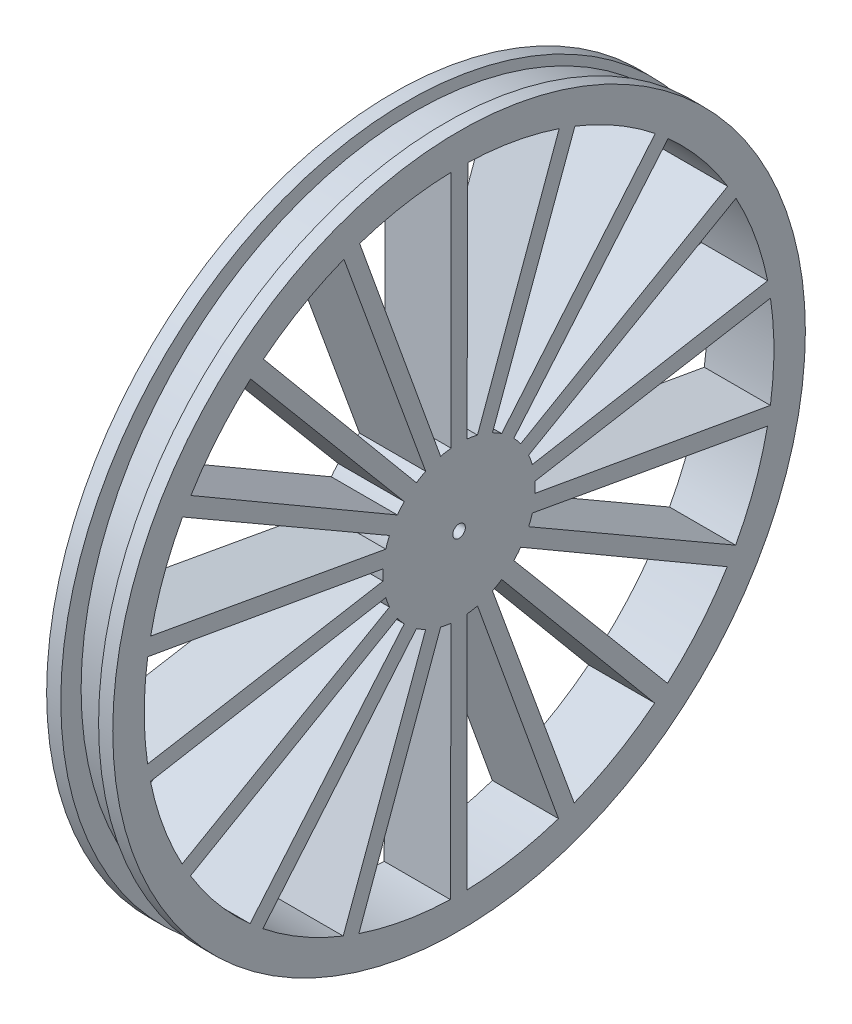
from build123d import *

# Parameters (mm, degrees)
SKETCH3_R                = 55
BOSS_EXTRUDE4_DEPTH      = 7
SKETCH4_R                = 55
SKETCH4_R_2              = 1
BOSS_EXTRUDE6_DEPTH      = 3.5
BOSS_EXTRUDE6_DEPTH_BACK = 1


with BuildPart() as part:
    # Sketch3 → Boss-Extrude4 (new body)
    with BuildSketch(Plane(origin=(0, 0, 0), x_dir=(0, 0, -1), z_dir=(1, 0, 0))):
        Circle(SKETCH3_R)
        with BuildLine():
            ThreePointArc((-6.766234132, -10.031354628), (-6.05, -10.478907386), (-5.304290876, -10.87540796))
            Line((-5.304290876, -10.87540796), (-18.398622374, -46.49183471))
            ThreePointArc((-18.398622374, -46.49183471), (-25.053308564, -43.270448692), (-31.160207408, -39.102959917))
            Line((-31.160207408, -39.102959917), (-6.766234132, -10.031354628))
        make_face(mode=Mode.SUBTRACT)
        with BuildLine():
            ThreePointArc((-2.927254937, -11.740578288), (-2.10114295, -11.916173811), (-1.264794406, -12.033714934))
            Line((-1.264794406, -12.033714934), (-1.387905707, -49.980733465))
            ThreePointArc((-1.387905707, -49.980733465), (-8.743044121, -49.22965752), (-15.907017008, -47.402181489))
            Line((-15.907017008, -47.402181489), (-2.927254937, -11.740578288))
        make_face(mode=Mode.SUBTRACT)
        with BuildLine():
            ThreePointArc((-11.631266521, -3.335212005), (-11.370280712, -4.138443734), (-11.053900037, -4.921513381))
            Line((-11.053900037, -4.921513381), (-43.978537734, -23.788405133))
            ThreePointArc((-43.978537734, -23.788405133), (-47.005656092, -17.043130445), (-49.005001868, -9.925209917))
            Line((-49.005001868, -9.925209917), (-11.631266521, -3.335212005))
        make_face(mode=Mode.SUBTRACT)
        with BuildLine():
            ThreePointArc((-9.789105632, -7.112201553), (-9.269137762, -7.777730077), (-8.704011584, -8.405366283))
            Line((-8.704011584, -8.405366283), (-33.190193649, -37.395334543))
            ThreePointArc((-33.190193649, -37.395334543), (-38.341774248, -32.092185148), (-42.655016919, -26.087344281))
            Line((-42.655016919, -26.087344281), (-9.789105632, -7.112201553))
        make_face(mode=Mode.SUBTRACT)
        with BuildLine():
            ThreePointArc((1.264794406, -12.033714934), (2.10114295, -11.916173811), (2.927254937, -11.740578288))
            Line((2.927254937, -11.740578288), (15.790212872, -47.441218128))
            ThreePointArc((15.790212872, -47.441218128), (8.621760477, -49.251043098), (1.264794406, -49.984000391))
            Line((1.264794406, -49.984000391), (1.264794406, -12.033714934))
        make_face(mode=Mode.SUBTRACT)
        with BuildLine():
            ThreePointArc((5.304290876, -10.87540796), (6.05, -10.478907386), (6.766234132, -10.031354628))
            Line((6.766234132, -10.031354628), (31.06379874, -39.179591726))
            ThreePointArc((31.06379874, -39.179591726), (24.946653518, -43.332026011), (18.284052947, -46.537011161))
            Line((18.284052947, -46.537011161), (5.304290876, -10.87540796))
        make_face(mode=Mode.SUBTRACT)
        with BuildLine():
            ThreePointArc((8.704011584, -8.405366283), (9.269137762, -7.777730077), (9.789105632, -7.112201553))
            Line((9.789105632, -7.112201553), (42.590632028, -26.192328333))
            ThreePointArc((42.590632028, -26.192328333), (38.262611971, -32.186527075), (33.09798486, -37.476971572))
            Line((33.09798486, -37.476971572), (8.704011584, -8.405366283))
        make_face(mode=Mode.SUBTRACT)
        with BuildLine():
            ThreePointArc((11.053900037, -4.921513381), (11.370280712, -4.138443734), (11.631266521, -3.335212005))
            Line((11.631266521, -3.335212005), (48.980406521, -10.045883585))
            ThreePointArc((48.980406521, -10.045883585), (46.963534725, -17.158857951), (43.919811324, -23.89665611))
            Line((43.919811324, -23.89665611), (11.053900037, -4.921513381))
        make_face(mode=Mode.SUBTRACT)
        with BuildLine():
            ThreePointArc((12.070525008, -0.844053332), (12.1, 0), (12.070525008, 0.844053332))
            Line((12.070525008, 0.844053332), (49.462421115, 7.312242984))
            ThreePointArc((49.462421115, 7.312242984), (49.809734905, 4.357787137), (49.980733465, 1.387905707))
            ThreePointArc((49.980733465, 1.387905707), (50, 0), (49.980733465, -1.387905707))
            ThreePointArc((49.980733465, -1.387905707), (49.804330314, -4.419126832), (49.444260356, -7.434051244))
            Line((49.444260356, -7.434051244), (12.070525008, -0.844053332))
        make_face(mode=Mode.SUBTRACT)
        with BuildLine():
            ThreePointArc((-12.070525008, 0.844053332), (-12.1, 0), (-12.070525008, -0.844053332))
            Line((-12.070525008, -0.844053332), (-49.462421115, -7.312242984))
            ThreePointArc((-49.462421115, -7.312242984), (-49.809734905, -4.357787137), (-49.980733465, -1.387905707))
            ThreePointArc((-49.980733465, -1.387905707), (-50, 0), (-49.980733465, 1.387905707))
            ThreePointArc((-49.980733465, 1.387905707), (-49.804330314, 4.419126832), (-49.444260356, 7.434051244))
            Line((-49.444260356, 7.434051244), (-12.070525008, 0.844053332))
        make_face(mode=Mode.SUBTRACT)
        with BuildLine():
            ThreePointArc((-11.053900037, 4.921513381), (-11.370280712, 4.138443734), (-11.631266521, 3.335212005))
            Line((-11.631266521, 3.335212005), (-48.980406521, 10.045883585))
            ThreePointArc((-48.980406521, 10.045883585), (-46.963534725, 17.158857951), (-43.919811324, 23.89665611))
            Line((-43.919811324, 23.89665611), (-11.053900037, 4.921513381))
        make_face(mode=Mode.SUBTRACT)
        with BuildLine():
            ThreePointArc((-8.704011584, 8.405366283), (-9.269137762, 7.777730077), (-9.789105632, 7.112201553))
            Line((-9.789105632, 7.112201553), (-42.590632028, 26.192328333))
            ThreePointArc((-42.590632028, 26.192328333), (-38.262611971, 32.186527075), (-33.09798486, 37.476971572))
            Line((-33.09798486, 37.476971572), (-8.704011584, 8.405366283))
        make_face(mode=Mode.SUBTRACT)
        with BuildLine():
            ThreePointArc((-5.304290876, 10.87540796), (-6.05, 10.478907386), (-6.766234132, 10.031354628))
            Line((-6.766234132, 10.031354628), (-31.06379874, 39.179591726))
            ThreePointArc((-31.06379874, 39.179591726), (-24.946653518, 43.332026011), (-18.284052947, 46.537011161))
            Line((-18.284052947, 46.537011161), (-5.304290876, 10.87540796))
        make_face(mode=Mode.SUBTRACT)
        with BuildLine():
            Line((-1.264794406, 49.984000391), (-1.264794406, 12.033714934))
            ThreePointArc((-1.264794406, 12.033714934), (-2.10114295, 11.916173811), (-2.927254937, 11.740578288))
            Line((-2.927254937, 11.740578288), (-15.790212872, 47.441218128))
            ThreePointArc((-15.790212872, 47.441218128), (-8.621760477, 49.251043098), (-1.264794406, 49.984000391))
        make_face(mode=Mode.SUBTRACT)
        Polygon((-0.586190908, 5.577233937), (0, 8.1), (0.586190908, 5.577233937), (1.684084696, 7.922995566), (1.732953368, 5.333482051), (3.294566809, 7.399718207), (2.80397745, 4.856631407), (4.761060544, 6.553037654), (3.752454263, 4.167522666), (6.019473086, 5.419957912), (4.536930818, 3.296273186), (7.014805771, 4.05), (5.123121726, 2.280960751), (7.703557782, 2.503037654), (5.485407631, 1.165959385), (8.055627352, 0.846680552), (5.607954901, 0), (8.055627352, -0.846680552), (5.485407631, -1.165959385), (7.703557782, -2.503037654), (5.123121726, -2.280960751), (7.014805771, -4.05), (4.536930818, -3.296273186), (6.019473086, -5.419957912), (3.752454263, -4.167522666), (4.761060544, -6.553037654), (2.80397745, -4.856631407), (3.294566809, -7.399718207), (1.732953368, -5.333482051), (1.684084696, -7.922995566), (0.586190908, -5.577233937), (0, -8.1), (-0.586190908, -5.577233937), (-1.684084696, -7.922995566), (-1.732953368, -5.333482051), (-3.294566809, -7.399718207), (-2.80397745, -4.856631407), (-4.761060544, -6.553037654), (-3.752454263, -4.167522666), (-6.019473086, -5.419957912), (-4.536930818, -3.296273186), (-7.014805771, -4.05), (-5.123121726, -2.280960751), (-7.703557782, -2.503037654), (-5.485407631, -1.165959385), (-8.055627352, -0.846680552), (-5.607954901, 0), (-8.055627352, 0.846680552), (-5.485407631, 1.165959385), (-7.703557782, 2.503037654), (-5.123121726, 2.280960751), (-7.014805771, 4.05), (-4.536930818, 3.296273186), (-6.019473086, 5.419957912), (-3.752454263, 4.167522666), (-4.761060544, 6.553037654), (-2.80397745, 4.856631407), (-3.294566809, 7.399718207), (-1.732953368, 5.333482051), (-1.684084696, 7.922995566), align=None, mode=Mode.SUBTRACT)
        with BuildLine():
            ThreePointArc((9.789105632, 7.112201553), (9.269137762, 7.777730077), (8.704011584, 8.405366283))
            Line((8.704011584, 8.405366283), (33.190193649, 37.395334543))
            ThreePointArc((33.190193649, 37.395334543), (38.341774248, 32.092185148), (42.655016919, 26.087344281))
            Line((42.655016919, 26.087344281), (9.789105632, 7.112201553))
        make_face(mode=Mode.SUBTRACT)
        with BuildLine():
            Line((11.053900037, 4.921513381), (43.978537734, 23.788405133))
            ThreePointArc((43.978537734, 23.788405133), (47.005656092, 17.043130445), (49.005001868, 9.925209917))
            Line((49.005001868, 9.925209917), (11.631266521, 3.335212005))
            ThreePointArc((11.631266521, 3.335212005), (11.370280712, 4.138443734), (11.053900037, 4.921513381))
        make_face(mode=Mode.SUBTRACT)
        with BuildLine():
            Line((15.907017008, 47.402181489), (2.927254937, 11.740578288))
            ThreePointArc((2.927254937, 11.740578288), (2.10114295, 11.916173811), (1.264794406, 12.033714934))
            Line((1.264794406, 12.033714934), (1.387905707, 49.980733465))
            ThreePointArc((1.387905707, 49.980733465), (8.743044121, 49.22965752), (15.907017008, 47.402181489))
        make_face(mode=Mode.SUBTRACT)
        with BuildLine():
            ThreePointArc((6.766234132, 10.031354628), (6.05, 10.478907386), (5.304290876, 10.87540796))
            Line((5.304290876, 10.87540796), (18.398622374, 46.49183471))
            ThreePointArc((18.398622374, 46.49183471), (25.053308564, 43.270448692), (31.160207408, 39.102959917))
            Line((31.160207408, 39.102959917), (6.766234132, 10.031354628))
        make_face(mode=Mode.SUBTRACT)
    extrude(amount=BOSS_EXTRUDE4_DEPTH)

    # Sketch4 → Boss-Extrude6 (add, two sides)
    with BuildSketch(Plane(origin=(7, 0, 0), x_dir=(0, 0, -1), z_dir=(1, 0, 0))) as boss_extrude6_sk:
        Circle(SKETCH4_R)
        with BuildLine():
            ThreePointArc((-11.053900037, 4.921513381), (-11.370280712, 4.138443734), (-11.631266521, 3.335212005))
            Line((-11.631266521, 3.335212005), (-48.980406521, 10.045883585))
            ThreePointArc((-48.980406521, 10.045883585), (-46.963534725, 17.158857951), (-43.919811324, 23.89665611))
            Line((-43.919811324, 23.89665611), (-11.053900037, 4.921513381))
        make_face(mode=Mode.SUBTRACT)
        with BuildLine():
            ThreePointArc((-8.704011584, 8.405366283), (-9.269137762, 7.777730077), (-9.789105632, 7.112201553))
            Line((-9.789105632, 7.112201553), (-42.590632028, 26.192328333))
            ThreePointArc((-42.590632028, 26.192328333), (-38.262611971, 32.186527075), (-33.09798486, 37.476971572))
            Line((-33.09798486, 37.476971572), (-8.704011584, 8.405366283))
        make_face(mode=Mode.SUBTRACT)
        with BuildLine():
            ThreePointArc((-5.304290876, 10.87540796), (-6.05, 10.478907386), (-6.766234132, 10.031354628))
            Line((-6.766234132, 10.031354628), (-31.06379874, 39.179591726))
            ThreePointArc((-31.06379874, 39.179591726), (-24.946653518, 43.332026011), (-18.284052947, 46.537011161))
            Line((-18.284052947, 46.537011161), (-5.304290876, 10.87540796))
        make_face(mode=Mode.SUBTRACT)
        with BuildLine():
            ThreePointArc((-1.264794406, 12.033714934), (-2.10114295, 11.916173811), (-2.927254937, 11.740578288))
            Line((-2.927254937, 11.740578288), (-15.790212872, 47.441218128))
            ThreePointArc((-15.790212872, 47.441218128), (-8.621760477, 49.251043098), (-1.264794406, 49.984000391))
            Line((-1.264794406, 49.984000391), (-1.264794406, 12.033714934))
        make_face(mode=Mode.SUBTRACT)
        with BuildLine():
            ThreePointArc((2.927254937, 11.740578288), (2.10114295, 11.916173811), (1.264794406, 12.033714934))
            Line((1.264794406, 12.033714934), (1.387905707, 49.980733465))
            ThreePointArc((1.387905707, 49.980733465), (8.743044121, 49.22965752), (15.907017008, 47.402181489))
            Line((15.907017008, 47.402181489), (2.927254937, 11.740578288))
        make_face(mode=Mode.SUBTRACT)
        with BuildLine():
            ThreePointArc((6.766234132, 10.031354628), (6.05, 10.478907386), (5.304290876, 10.87540796))
            Line((5.304290876, 10.87540796), (18.398622374, 46.49183471))
            ThreePointArc((18.398622374, 46.49183471), (25.053308564, 43.270448692), (31.160207408, 39.102959917))
            Line((31.160207408, 39.102959917), (6.766234132, 10.031354628))
        make_face(mode=Mode.SUBTRACT)
        with BuildLine():
            ThreePointArc((9.789105632, 7.112201553), (9.269137762, 7.777730077), (8.704011584, 8.405366283))
            Line((8.704011584, 8.405366283), (33.190193649, 37.395334543))
            ThreePointArc((33.190193649, 37.395334543), (38.341774248, 32.092185148), (42.655016919, 26.087344281))
            Line((42.655016919, 26.087344281), (9.789105632, 7.112201553))
        make_face(mode=Mode.SUBTRACT)
        with BuildLine():
            ThreePointArc((11.631266521, 3.335212005), (11.370280712, 4.138443734), (11.053900037, 4.921513381))
            Line((11.053900037, 4.921513381), (43.978537734, 23.788405133))
            ThreePointArc((43.978537734, 23.788405133), (47.005656092, 17.043130445), (49.005001868, 9.925209917))
            Line((49.005001868, 9.925209917), (11.631266521, 3.335212005))
        make_face(mode=Mode.SUBTRACT)
        with BuildLine():
            Line((12.070525008, 0.844053332), (49.462421115, 7.312242984))
            ThreePointArc((49.462421115, 7.312242984), (49.999962082, -0.06157732), (49.444260356, -7.434051244))
            Line((49.444260356, -7.434051244), (12.070525008, -0.844053332))
            ThreePointArc((12.070525008, -0.844053332), (12.1, 0), (12.070525008, 0.844053332))
        make_face(mode=Mode.SUBTRACT)
        with BuildLine():
            ThreePointArc((11.053900037, -4.921513381), (11.370280712, -4.138443734), (11.631266521, -3.335212005))
            Line((11.631266521, -3.335212005), (48.980406521, -10.045883585))
            ThreePointArc((48.980406521, -10.045883585), (46.963534725, -17.158857951), (43.919811324, -23.89665611))
            Line((43.919811324, -23.89665611), (11.053900037, -4.921513381))
        make_face(mode=Mode.SUBTRACT)
        with BuildLine():
            ThreePointArc((8.704011584, -8.405366283), (9.269137762, -7.777730077), (9.789105632, -7.112201553))
            Line((9.789105632, -7.112201553), (42.590632028, -26.192328333))
            ThreePointArc((42.590632028, -26.192328333), (38.262611971, -32.186527075), (33.09798486, -37.476971572))
            Line((33.09798486, -37.476971572), (8.704011584, -8.405366283))
        make_face(mode=Mode.SUBTRACT)
        with BuildLine():
            ThreePointArc((5.304290876, -10.87540796), (6.05, -10.478907386), (6.766234132, -10.031354628))
            Line((6.766234132, -10.031354628), (31.06379874, -39.179591726))
            ThreePointArc((31.06379874, -39.179591726), (24.946653518, -43.332026011), (18.284052947, -46.537011161))
            Line((18.284052947, -46.537011161), (5.304290876, -10.87540796))
        make_face(mode=Mode.SUBTRACT)
        with BuildLine():
            ThreePointArc((1.264794406, -12.033714934), (2.10114295, -11.916173811), (2.927254937, -11.740578288))
            Line((2.927254937, -11.740578288), (15.790212872, -47.441218128))
            ThreePointArc((15.790212872, -47.441218128), (8.621760477, -49.251043098), (1.264794406, -49.984000391))
            Line((1.264794406, -49.984000391), (1.264794406, -12.033714934))
        make_face(mode=Mode.SUBTRACT)
        with BuildLine():
            ThreePointArc((-2.927254937, -11.740578288), (-2.10114295, -11.916173811), (-1.264794406, -12.033714934))
            Line((-1.264794406, -12.033714934), (-1.387905707, -49.980733465))
            ThreePointArc((-1.387905707, -49.980733465), (-8.743044121, -49.22965752), (-15.907017008, -47.402181489))
            Line((-15.907017008, -47.402181489), (-2.927254937, -11.740578288))
        make_face(mode=Mode.SUBTRACT)
        with BuildLine():
            ThreePointArc((-6.766234132, -10.031354628), (-6.05, -10.478907386), (-5.304290876, -10.87540796))
            Line((-5.304290876, -10.87540796), (-18.398622374, -46.49183471))
            ThreePointArc((-18.398622374, -46.49183471), (-25.053308564, -43.270448692), (-31.160207408, -39.102959917))
            Line((-31.160207408, -39.102959917), (-6.766234132, -10.031354628))
        make_face(mode=Mode.SUBTRACT)
        with BuildLine():
            ThreePointArc((-9.789105632, -7.112201553), (-9.269137762, -7.777730077), (-8.704011584, -8.405366283))
            Line((-8.704011584, -8.405366283), (-33.190193649, -37.395334543))
            ThreePointArc((-33.190193649, -37.395334543), (-38.341774248, -32.092185148), (-42.655016919, -26.087344281))
            Line((-42.655016919, -26.087344281), (-9.789105632, -7.112201553))
        make_face(mode=Mode.SUBTRACT)
        with BuildLine():
            ThreePointArc((-11.631266521, -3.335212005), (-11.370280712, -4.138443734), (-11.053900037, -4.921513381))
            Line((-11.053900037, -4.921513381), (-43.978537734, -23.788405133))
            ThreePointArc((-43.978537734, -23.788405133), (-47.005656092, -17.043130445), (-49.005001868, -9.925209917))
            Line((-49.005001868, -9.925209917), (-11.631266521, -3.335212005))
        make_face(mode=Mode.SUBTRACT)
        with BuildLine():
            ThreePointArc((-12.070525008, 0.844053332), (-12.1, 0), (-12.070525008, -0.844053332))
            Line((-12.070525008, -0.844053332), (-49.462421115, -7.312242984))
            ThreePointArc((-49.462421115, -7.312242984), (-49.999962082, 0.06157732), (-49.444260356, 7.434051244))
            Line((-49.444260356, 7.434051244), (-12.070525008, 0.844053332))
        make_face(mode=Mode.SUBTRACT)
        Circle(SKETCH4_R_2, mode=Mode.SUBTRACT)
    extrude(amount=BOSS_EXTRUDE6_DEPTH)
    extrude(boss_extrude6_sk.sketch, amount=-BOSS_EXTRUDE6_DEPTH_BACK)

    # Sketch5 → Cut-Revolve1 (revolve, cut)
    with BuildSketch(Plane(origin=(0, -0.003976663, -1.22574059), x_dir=(-1, 0, 0), z_dir=(0, -0.003244277, -0.999994737))):
        Polygon((-8.25, 53), (-2.25, 53), (-2.25, 55), (-2.25, 56.236567795), (-8.25, 56.236567795), (-8.25, 55), align=None)
    revolve(axis=Axis((-14.716432805, -0.003976663, -1.22574059), (1, 0, 0)), mode=Mode.SUBTRACT)


solid = part.part
